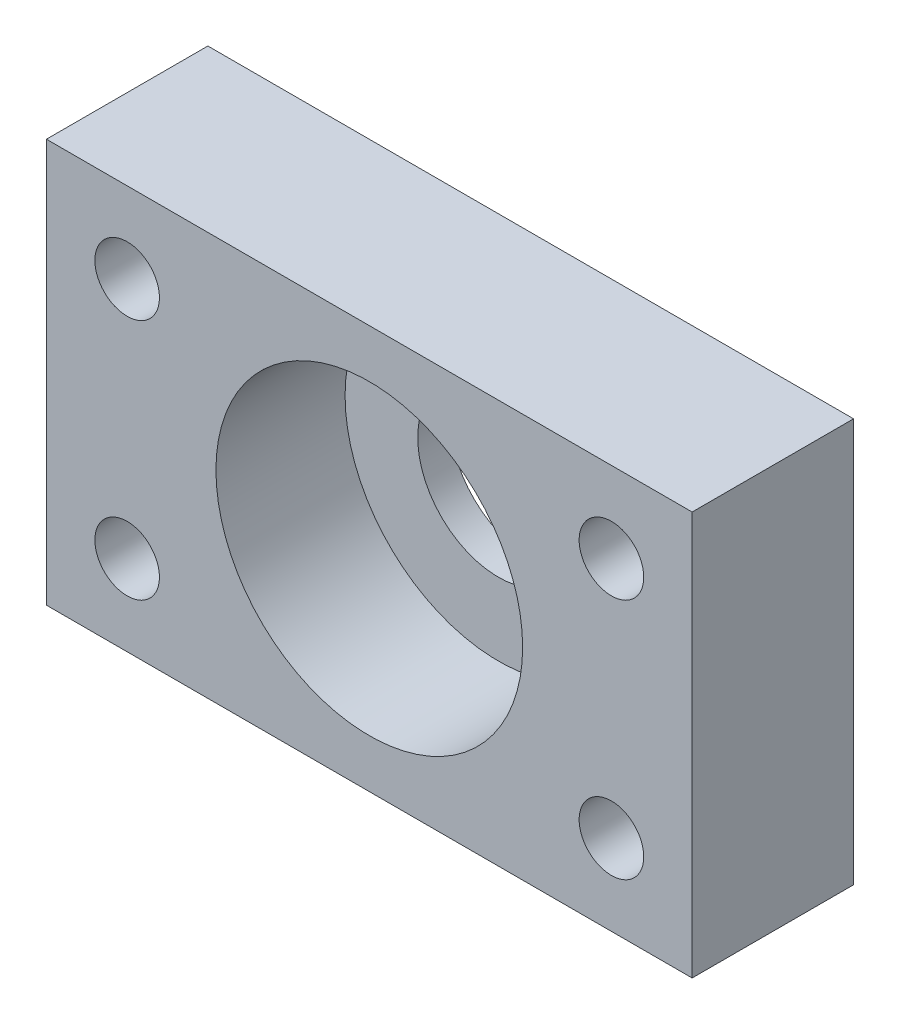
from build123d import *

# Parameters (mm, degrees)
ESQUISSE1_W        = 40
ESQUISSE1_H        = 25
ESQUISSE1_R        = 2
ESQUISSE1_R_2      = 9.5
BOSS_EXTRU_1_DEPTH = 10
ESQUISSE1_4_R      = 9.5
ESQUISSE1_4_R_2    = 5
BOSS_EXTRU_2_DEPTH = 2


with BuildPart() as part:
    # Esquisse1 → Boss.-Extru.1 (new body)
    with BuildSketch(Plane.XY):
        with Locations((-14.823595047, -22.249813872)):
            Rectangle(ESQUISSE1_W, ESQUISSE1_H)
        with Locations((-29.823595047, -29.749813872)):
            Circle(ESQUISSE1_R, mode=Mode.SUBTRACT)
        with Locations((0.176404953, -29.749813872)):
            Circle(ESQUISSE1_R, mode=Mode.SUBTRACT)
        with Locations((-14.823595047, -22.249813872)):
            Circle(ESQUISSE1_R_2, mode=Mode.SUBTRACT)
        with Locations((-29.823595047, -14.749813872)):
            Circle(ESQUISSE1_R, mode=Mode.SUBTRACT)
        with Locations((0.176404953, -14.749813872)):
            Circle(ESQUISSE1_R, mode=Mode.SUBTRACT)
    extrude(amount=BOSS_EXTRU_1_DEPTH)

    # Esquisse1_4 → Boss.-Extru.2 (add)
    with BuildSketch(Plane.XY):
        with Locations((-14.823595047, -22.249813872)):
            Circle(ESQUISSE1_4_R)
        with Locations((-14.823595047, -22.249813872)):
            Circle(ESQUISSE1_4_R_2, mode=Mode.SUBTRACT)
    extrude(amount=BOSS_EXTRU_2_DEPTH)


solid = part.part
